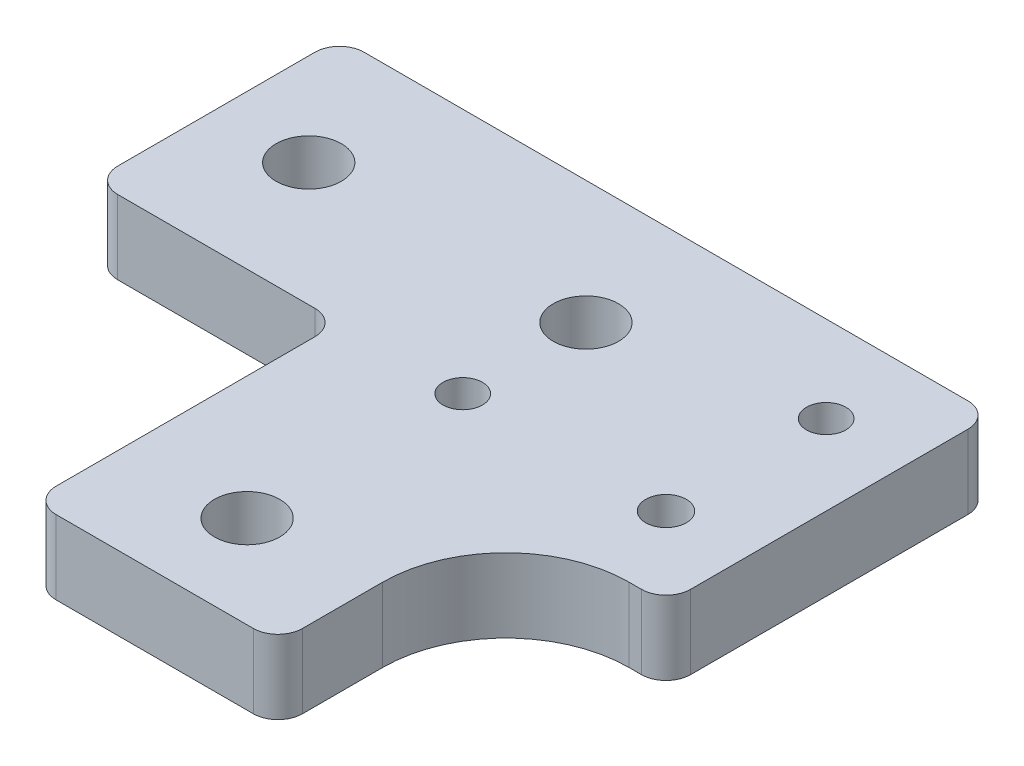
from build123d import *

# Parameters (mm, degrees)
BOSS_EXTRUDE1_DEPTH   = 6
M5_CLEARANCE_HOLE1_D  = 5.3
M3_CLEARANCE_HOLE1_D  = 3.2
M4X0_7_TAPPED_HOLE1_D = 3.3


with BuildPart() as part:
    # Sketch1 → Boss-Extrude1 (new body)
    with BuildSketch(Plane(origin=(0, 0, 0), x_dir=(1, 0, 0), z_dir=(0, 1, 0))):
        with BuildLine():
            Line((22, 0.037275986), (38, 0.037275986))
            ThreePointArc((38, 0.037275986), (39.414213562, 0.623062423), (40, 2.037275986))
            Line((40, 2.037275986), (40, 8.537275986))
            ThreePointArc((40, 8.537275986), (42.928932188, 15.608343798), (50, 18.537275986))
            Line((50, 18.537275986), (51, 18.537275986))
            ThreePointArc((51, 18.537275986), (52.414213562, 19.123062423), (53, 20.537275986))
            Line((53, 20.537275986), (53, 43.037275986))
            ThreePointArc((53, 43.037275986), (52.414213562, 44.451489548), (51, 45.037275986))
            Line((51, 45.037275986), (2, 45.037275986))
            ThreePointArc((2, 45.037275986), (0.585786438, 44.451489548), (0, 43.037275986))
            Line((0, 43.037275986), (0, 27.037275986))
            ThreePointArc((0, 27.037275986), (0.585786438, 25.623062423), (2, 25.037275986))
            Line((2, 25.037275986), (18, 25.037275986))
            ThreePointArc((18, 25.037275986), (19.414213562, 24.451489548), (20, 23.037275986))
            Line((20, 23.037275986), (20, 2.037275986))
            ThreePointArc((20, 2.037275986), (20.585786438, 0.623062423), (22, 0.037275986))
        make_face()
    extrude(amount=BOSS_EXTRUDE1_DEPTH)

    # M5 Clearance Hole1 (through all)
    with Locations(Plane(origin=(0, 0, 0), x_dir=(-1, 0, 0), z_dir=(0, -1, 0))):
        with Locations((-7.5, 35.037275986), (-30, 35.037275986), (-30, 7.537275986)):
            Hole(M5_CLEARANCE_HOLE1_D / 2)

    # M3 Clearance Hole1 (through all)
    with Locations(Plane(origin=(0, 0, 0), x_dir=(-1, 0, 0), z_dir=(0, -1, 0))):
        with Locations((-30, 25.037275986), (-46.5, 38.037275986)):
            Hole(M3_CLEARANCE_HOLE1_D / 2)

    # M4x0.7 Tapped Hole1 (through all)
    with Locations(Plane(origin=(0, 0, 0), x_dir=(-1, 0, 0), z_dir=(0, -1, 0))):
        with Locations((-46.5, 25.037275986)):
            Hole(M4X0_7_TAPPED_HOLE1_D / 2)


solid = part.part
